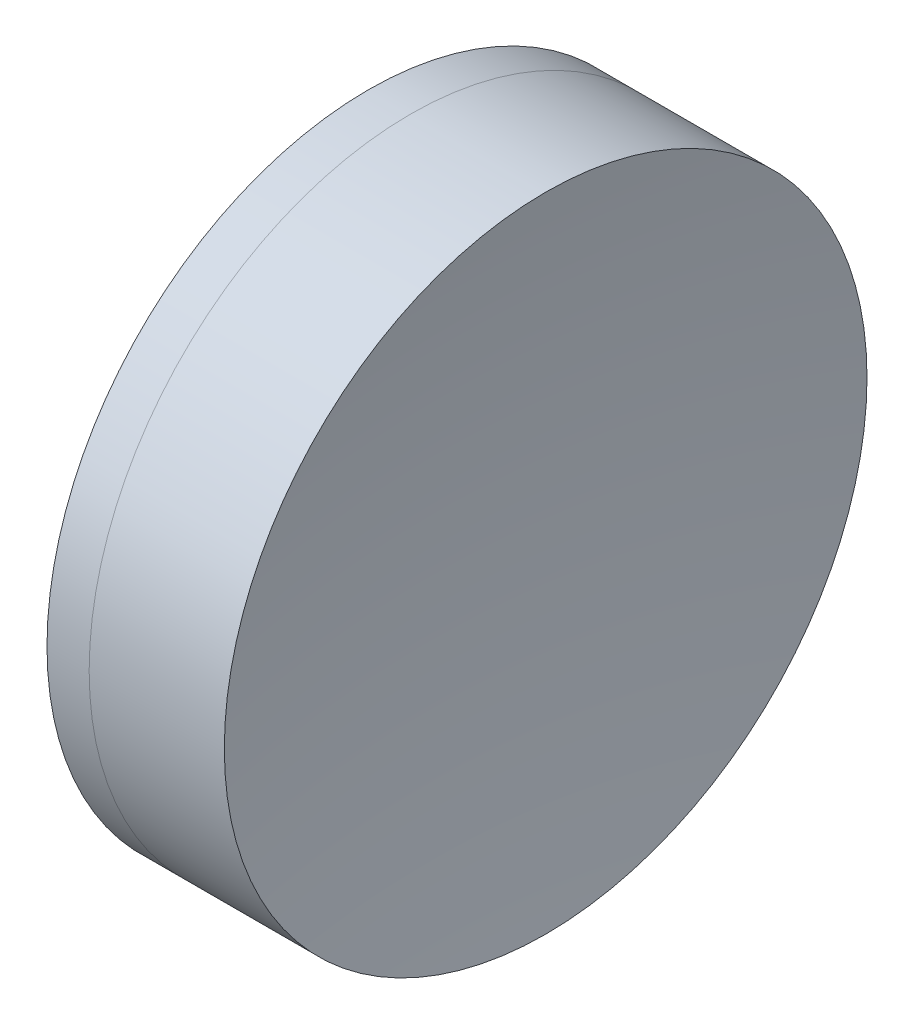
from build123d import *


with BuildPart() as part:
    # 草图1 one side → 旋转1 (revolve)
    with BuildSketch(Plane(origin=(0, 0, 0), x_dir=(1, 0, 0), z_dir=(0, 1, 0)), mode=Mode.PRIVATE) as revolve_1_sk:
        with BuildLine():
            ThreePointArc((98.430752238, 15), (95.783400678, 7.706704592), (94.884883839, 0))
            Line((94.884883839, 0), (103.384883839, 0))
            ThreePointArc((103.384883839, 0), (102.631156385, 7.647150036), (100.398981175, 15))
            Line((100.398981175, 15), (98.430752238, 15))
        make_face()
    revolve(revolve_1_sk.sketch.rotate(Axis((-0.816062176, 0, 0), (1, 0, 0)), 180), axis=Axis((-0.816062176, 0, 0), (1, 0, 0)))  # turned: the seam where the file's is


with BuildPart() as body_2:
    # 草图2 one side → 旋转2 (revolve)
    with BuildSketch(Plane(origin=(0, 0, 0), x_dir=(1, 0, 0), z_dir=(0, 1, 0)), mode=Mode.PRIVATE) as revolve_2_sk:
        with BuildLine():
            Line((106.708443208, 15), (100.398981175, 15))
            ThreePointArc((100.398981175, 15), (102.631156385, 7.647150036), (103.384883839, 0))
            Line((103.384883839, 0), (105.584883839, 0))
            ThreePointArc((105.584883839, 0), (105.86616657, 7.521010332), (106.708443208, 15))
        make_face()
    revolve(revolve_2_sk.sketch.rotate(Axis((-0.551919993, 0, 0), (1, 0, 0)), 180), axis=Axis((-0.551919993, 0, 0), (1, 0, 0)))  # turned: the seam where the file's is


solid = Compound([part.part, body_2.part])
